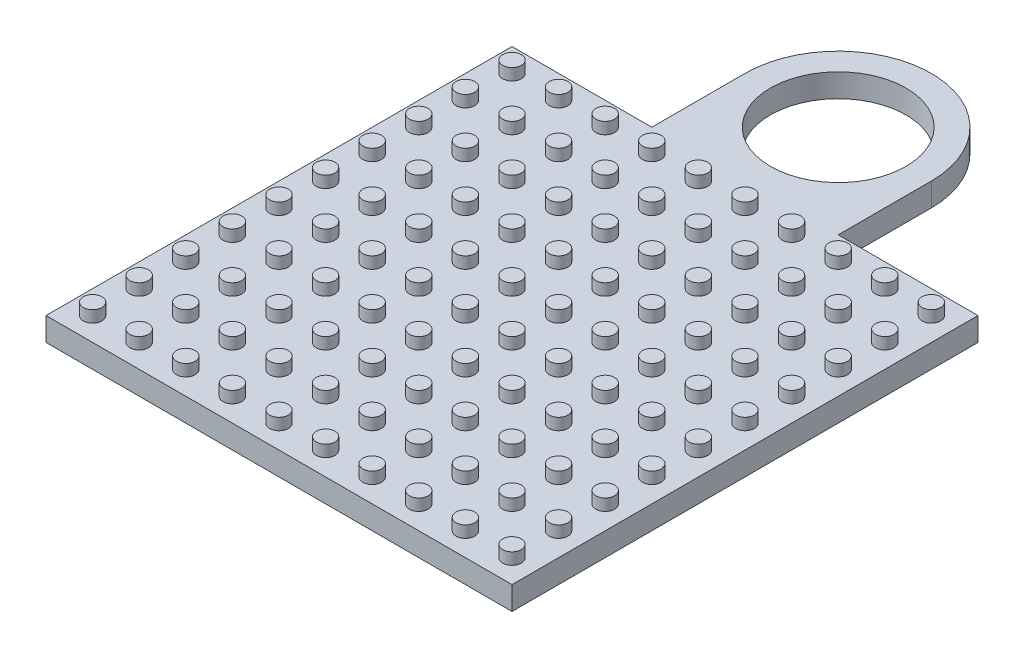
from build123d import *

# Parameters (mm, degrees)
SKETCH1_W               = 10
SKETCH1_H               = 10
PLATE_DEPTH             = 0.5
SKETCH2_R               = 0.2
ROD_DEPTH               = 0.25
LPATTERN1_COUNT         = 10
LPATTERN1_PITCH         = 1
LPATTERN1_COUNT_DIR2    = 10
LPATTERN1_PITCH_DIR2    = 1
BOSS_EXTRUDE3_DEPTH     = 0.5
SKETCH5_R               = 1.455938962
CUT_EXTRUDE1_DEPTH      = 0.5
CUT_EXTRUDE1_DEPTH_BACK = 1.5


with BuildPart() as part:
    # Sketch1 → Plate (new body)
    with BuildSketch(Plane(origin=(0, 0, 0), x_dir=(1, 0, 0), z_dir=(0, 1, 0))):
        Rectangle(SKETCH1_W, SKETCH1_H)
    extrude(amount=PLATE_DEPTH)

    # Sketch2 → Rod (add)
    with BuildSketch(Plane(origin=(0, 0.5, 0), x_dir=(1, 0, 0), z_dir=(0, 1, 0))):
        with Locations((-4.5, -4.5)):
            Circle(SKETCH2_R)
    rod = extrude(amount=ROD_DEPTH)

    # LPattern1: Rod 10 × 10
    with Locations(*[(i * LPATTERN1_PITCH, 0, -j * LPATTERN1_PITCH_DIR2) for i in range(LPATTERN1_COUNT) for j in range(LPATTERN1_COUNT_DIR2) if (i, j) != (0, 0)]):
        add(rod)

    # Sketch4 → Boss-Extrude3 (add)
    with BuildSketch(Plane(origin=(0, 0, 0), x_dir=(1, 0, 0), z_dir=(0, 1, 0))):
        with BuildLine():
            Line((-2, 7), (-2, 5))
            Line((-2, 5), (2, 5))
            Line((2, 5), (2, 7))
            ThreePointArc((2, 7), (0, 9), (-2, 7))
        make_face()
    extrude(amount=BOSS_EXTRUDE3_DEPTH)

    # Sketch5 → Cut-Extrude1 (cut, two sides)
    with BuildSketch(Plane(origin=(0, 0.5, 0), x_dir=(1, 0, 0), z_dir=(0, 1, 0))) as cut_extrude1_sk:
        with Locations((0, 7)):
            Circle(SKETCH5_R)
    extrude(amount=CUT_EXTRUDE1_DEPTH, mode=Mode.SUBTRACT)
    extrude(cut_extrude1_sk.sketch, amount=-CUT_EXTRUDE1_DEPTH_BACK, mode=Mode.SUBTRACT)


solid = part.part
